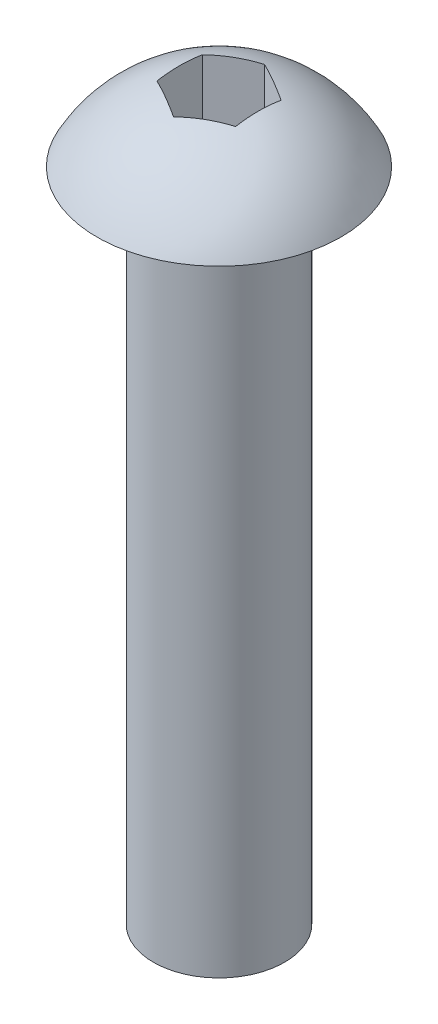
from build123d import *

# Parameters (mm, degrees)
CUT_EXTRUDE1_DEPTH = 10


with BuildPart() as part:
    # Sketch1 → Revolve1 (revolve)
    with BuildSketch(Plane.XY):
        with BuildLine():
            Line((0, 0), (0, -25))
            Line((0, -25), (2.5, -25))
            Line((2.5, -25), (2.5, 0))
            Line((2.5, 0), (4.65, 0))
            ThreePointArc((4.65, 0), (2.713968497, 2.045965539), (0, 2.8))
            Line((0, 2.8), (0, 0))
        make_face()
    revolve(axis=Axis((0, 0, 0), (0, -1, 0)))

    # Sketch2 → Cut-Extrude1 (cut)
    with BuildSketch(Plane(origin=(0, 0, 0), x_dir=(1, 0, 0), z_dir=(0, 1, 0))):
        Polygon((0, 1.732050808), (-1.5, 0.866025404), (-1.5, -0.866025404), (0, -1.732050808), (1.5, -0.866025404), (1.5, 0.866025404), align=None)
    extrude(amount=CUT_EXTRUDE1_DEPTH, mode=Mode.SUBTRACT)


solid = part.part
